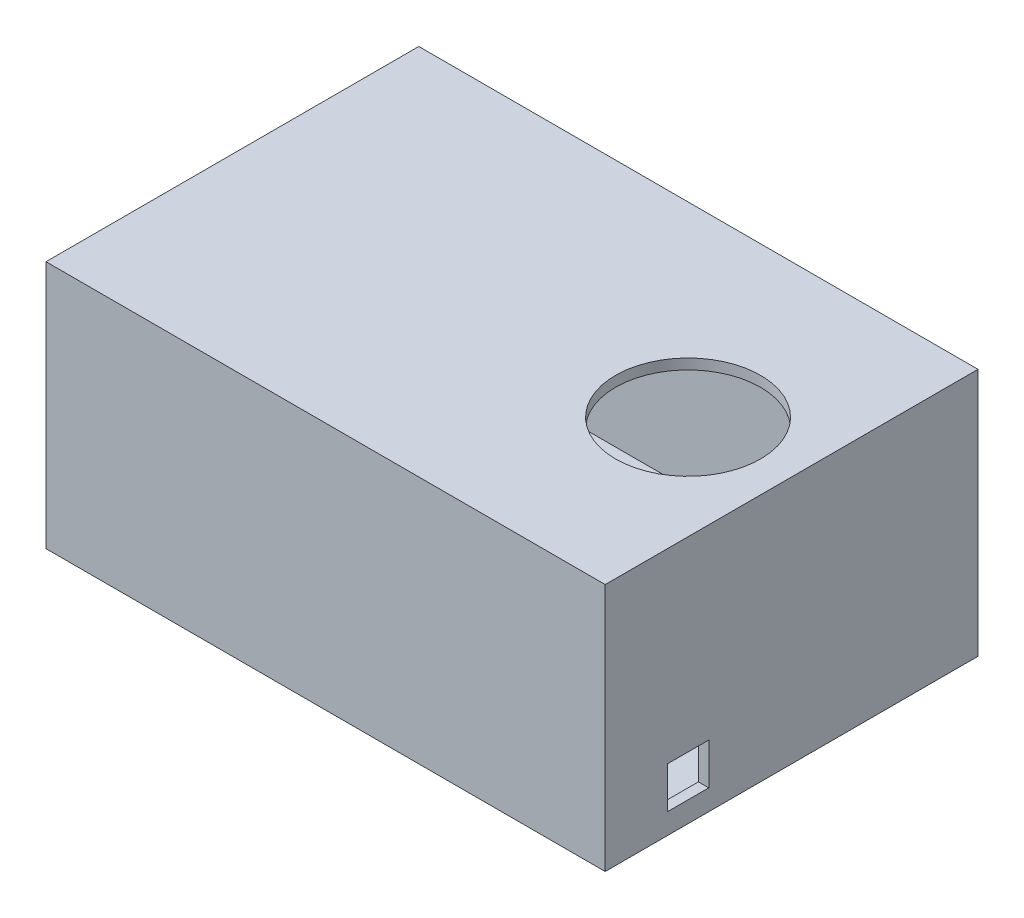
from build123d import *

# Parameters (mm, degrees)
SKETCH1_W             = 342.9
SKETCH1_H             = 228.6
MAIN_BOX_DEPTH        = 152.4
SHELL1_T              = 6.35
TOP_HOLE_REACH        = 154.4
SKETCH2_R             = 44.45
SIDE_HOLE_REACH       = 344.9
SKETCH3_R             = 44.45
POWER_CORD_HOLE_REACH = 344.9
SKETCH4_W             = 25.4
SKETCH4_H             = 25.4


with BuildPart() as part:
    # Sketch1 → main box (new body)
    with BuildSketch(Plane(origin=(0, 0, 0), x_dir=(1, 0, 0), z_dir=(0, 1, 0))):
        with Locations((171.45, 114.3)):
            Rectangle(SKETCH1_W, SKETCH1_H)
    extrude(amount=MAIN_BOX_DEPTH)

    # Shell1 (no face opened: a closed hollow body)
    add(offset(amount=-SHELL1_T, mode=Mode.PRIVATE), mode=Mode.SUBTRACT)

    # Sketch2 → top hole (cut, up to next)
    with BuildSketch(Plane(origin=(0, 152.4, 0), x_dir=(1, 0, 0), z_dir=(0, 1, 0)), mode=Mode.PRIVATE) as top_hole_sk1:
        with Locations((279.4, 114.3)):
            Circle(SKETCH2_R)
    top_hole_tool1 = extrude(top_hole_sk1.sketch, amount=-TOP_HOLE_REACH, mode=Mode.PRIVATE) & part.part
    add(top_hole_tool1.solids().sort_by_distance((279.4, 152.4, -114.3))[0], mode=Mode.SUBTRACT)

    # Sketch3 → side hole (cut, up to next)
    with BuildSketch(Plane.ZY, mode=Mode.PRIVATE) as side_hole_sk1:
        with Locations((-114.3, 76.2)):
            Circle(SKETCH3_R)
    side_hole_tool1 = extrude(side_hole_sk1.sketch, amount=-SIDE_HOLE_REACH, mode=Mode.PRIVATE) & part.part
    add(side_hole_tool1.solids().sort_by_distance((0, 76.2, -114.3))[0], mode=Mode.SUBTRACT)

    # Sketch4 → power cord hole (cut, up to next)
    with BuildSketch(Plane(origin=(342.9, 0, 0), x_dir=(0, 0, -1), z_dir=(1, 0, 0)), mode=Mode.PRIVATE) as power_cord_hole_sk1:
        with Locations((50.8, 25.4)):
            Rectangle(SKETCH4_W, SKETCH4_H)
    power_cord_hole_tool1 = extrude(power_cord_hole_sk1.sketch, amount=-POWER_CORD_HOLE_REACH, mode=Mode.PRIVATE) & part.part
    add(power_cord_hole_tool1.solids().sort_by_distance((342.9, 25.4, -50.8))[0], mode=Mode.SUBTRACT)


solid = part.part
